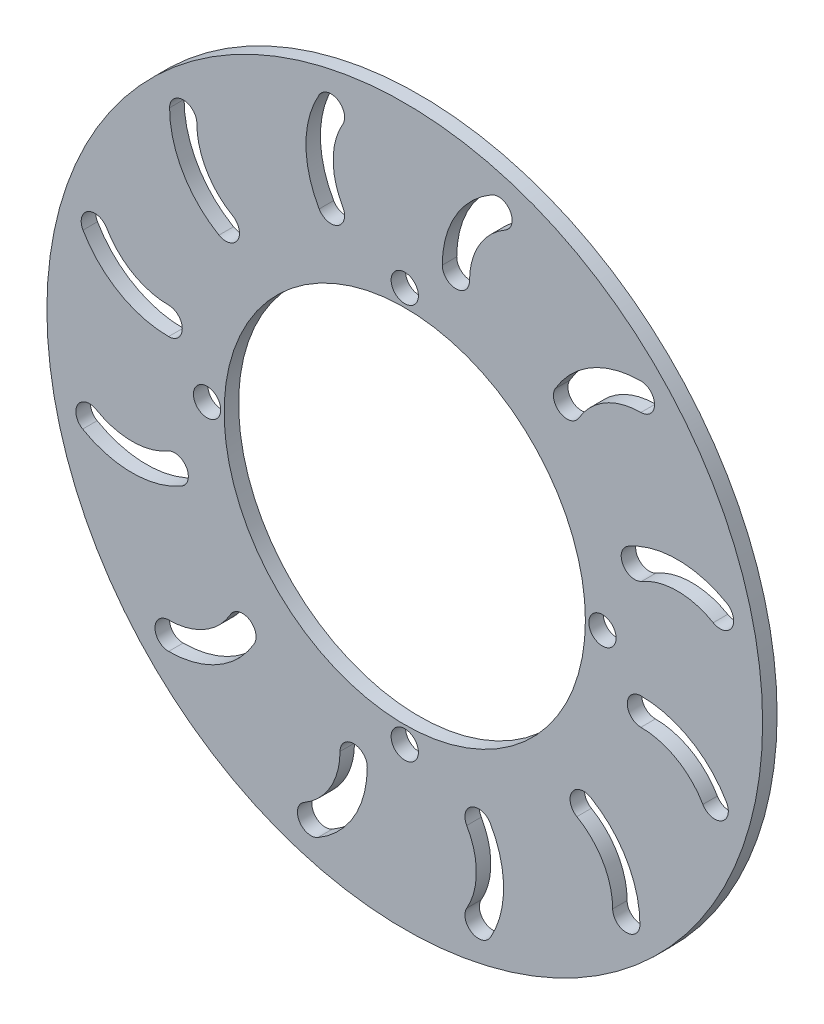
from build123d import *

# Parameters (mm, degrees)
SKETCH1_R           = 105
SKETCH1_R_2         = 53
SKETCH1_R_3         = 4
BOSS_EXTRUDE1_DEPTH = 4.25


with BuildPart() as part:
    # Sketch1 → Boss-Extrude1 (new body)
    with BuildSketch(Plane.XY):
        Circle(SKETCH1_R)
        Circle(SKETCH1_R_2, mode=Mode.SUBTRACT)
        with Locations((0, 58)):
            Circle(SKETCH1_R_3, mode=Mode.SUBTRACT)
        with Locations((58, 0)):
            Circle(SKETCH1_R_3, mode=Mode.SUBTRACT)
        with Locations((0, -58)):
            Circle(SKETCH1_R_3, mode=Mode.SUBTRACT)
        with Locations((-58, 0)):
            Circle(SKETCH1_R_3, mode=Mode.SUBTRACT)
        with BuildLine():
            ThreePointArc((94.5, 25.11473671), (80, 29), (65.5, 25.11473671))
            ThreePointArc((65.5, 25.11473671), (64.035898385, 19.650635095), (69.5, 18.186533479))
            ThreePointArc((69.5, 18.186533479), (80, 21), (90.5, 18.186533479))
            ThreePointArc((90.5, 18.186533479), (95.964101615, 19.650635095), (94.5, 25.11473671))
        make_face(mode=Mode.SUBTRACT)
        with BuildLine():
            ThreePointArc((94.396769013, -25.5), (83.782032303, -14.88526329), (69.282032303, -11))
            ThreePointArc((69.282032303, -11), (65.282032303, -15), (69.282032303, -19))
            ThreePointArc((69.282032303, -19), (79.782032303, -21.813466521), (87.468565782, -29.5))
            ThreePointArc((87.468565782, -29.5), (92.932667397, -30.964101615), (94.396769013, -25.5))
        make_face(mode=Mode.SUBTRACT)
        with BuildLine():
            ThreePointArc((69, -69.282032303), (65.11473671, -54.782032303), (54.5, -44.167295593))
            ThreePointArc((54.5, -44.167295593), (49.035898385, -45.631397208), (50.5, -51.095498823))
            ThreePointArc((50.5, -51.095498823), (58.186533479, -58.782032303), (61, -69.282032303))
            ThreePointArc((61, -69.282032303), (65, -73.282032303), (69, -69.282032303))
        make_face(mode=Mode.SUBTRACT)
        with BuildLine():
            ThreePointArc((25.11473671, -94.5), (29, -80), (25.11473671, -65.5))
            ThreePointArc((25.11473671, -65.5), (19.650635095, -64.035898385), (18.186533479, -69.5))
            ThreePointArc((18.186533479, -69.5), (21, -80), (18.186533479, -90.5))
            ThreePointArc((18.186533479, -90.5), (19.650635095, -95.964101615), (25.11473671, -94.5))
        make_face(mode=Mode.SUBTRACT)
        with BuildLine():
            ThreePointArc((-25.5, -94.396769013), (-14.88526329, -83.782032303), (-11, -69.282032303))
            ThreePointArc((-11, -69.282032303), (-15, -65.282032303), (-19, -69.282032303))
            ThreePointArc((-19, -69.282032303), (-21.813466521, -79.782032303), (-29.5, -87.468565782))
            ThreePointArc((-29.5, -87.468565782), (-30.964101615, -92.932667397), (-25.5, -94.396769013))
        make_face(mode=Mode.SUBTRACT)
        with BuildLine():
            ThreePointArc((-69.282032303, -69), (-54.782032303, -65.11473671), (-44.167295593, -54.5))
            ThreePointArc((-44.167295593, -54.5), (-45.631397208, -49.035898385), (-51.095498823, -50.5))
            ThreePointArc((-51.095498823, -50.5), (-58.782032303, -58.186533479), (-69.282032303, -61))
            ThreePointArc((-69.282032303, -61), (-73.282032303, -65), (-69.282032303, -69))
        make_face(mode=Mode.SUBTRACT)
        with BuildLine():
            ThreePointArc((-94.5, -25.11473671), (-80, -29), (-65.5, -25.11473671))
            ThreePointArc((-65.5, -25.11473671), (-64.035898385, -19.650635095), (-69.5, -18.186533479))
            ThreePointArc((-69.5, -18.186533479), (-80, -21), (-90.5, -18.186533479))
            ThreePointArc((-90.5, -18.186533479), (-95.964101615, -19.650635095), (-94.5, -25.11473671))
        make_face(mode=Mode.SUBTRACT)
        with BuildLine():
            ThreePointArc((-94.396769013, 25.5), (-83.782032303, 14.88526329), (-69.282032303, 11))
            ThreePointArc((-69.282032303, 11), (-65.282032303, 15), (-69.282032303, 19))
            ThreePointArc((-69.282032303, 19), (-79.782032303, 21.813466521), (-87.468565782, 29.5))
            ThreePointArc((-87.468565782, 29.5), (-92.932667397, 30.964101615), (-94.396769013, 25.5))
        make_face(mode=Mode.SUBTRACT)
        with BuildLine():
            ThreePointArc((-69, 69.282032303), (-65.11473671, 54.782032303), (-54.5, 44.167295593))
            ThreePointArc((-54.5, 44.167295593), (-49.035898385, 45.631397208), (-50.5, 51.095498823))
            ThreePointArc((-50.5, 51.095498823), (-58.186533479, 58.782032303), (-61, 69.282032303))
            ThreePointArc((-61, 69.282032303), (-65, 73.282032303), (-69, 69.282032303))
        make_face(mode=Mode.SUBTRACT)
        with BuildLine():
            ThreePointArc((-25.11473671, 94.5), (-29, 80), (-25.11473671, 65.5))
            ThreePointArc((-25.11473671, 65.5), (-19.650635095, 64.035898385), (-18.186533479, 69.5))
            ThreePointArc((-18.186533479, 69.5), (-21, 80), (-18.186533479, 90.5))
            ThreePointArc((-18.186533479, 90.5), (-19.650635095, 95.964101615), (-25.11473671, 94.5))
        make_face(mode=Mode.SUBTRACT)
        with BuildLine():
            ThreePointArc((25.5, 94.396769013), (14.88526329, 83.782032303), (11, 69.282032303))
            ThreePointArc((11, 69.282032303), (15, 65.282032303), (19, 69.282032303))
            ThreePointArc((19, 69.282032303), (21.813466521, 79.782032303), (29.5, 87.468565782))
            ThreePointArc((29.5, 87.468565782), (30.964101615, 92.932667397), (25.5, 94.396769013))
        make_face(mode=Mode.SUBTRACT)
        with BuildLine():
            ThreePointArc((69.282032303, 69), (54.782032303, 65.11473671), (44.167295593, 54.5))
            ThreePointArc((44.167295593, 54.5), (45.631397208, 49.035898385), (51.095498823, 50.5))
            ThreePointArc((51.095498823, 50.5), (58.782032303, 58.186533479), (69.282032303, 61))
            ThreePointArc((69.282032303, 61), (73.282032303, 65), (69.282032303, 69))
        make_face(mode=Mode.SUBTRACT)
    extrude(amount=BOSS_EXTRUDE1_DEPTH)


solid = part.part
